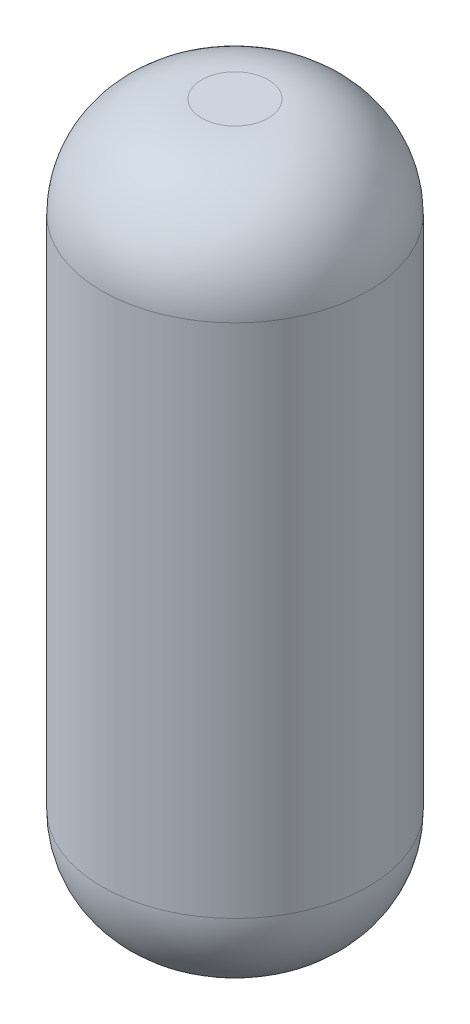
from build123d import *

# Parameters (mm, degrees)
CROQUIS1_R              = 4
SALIENTE_EXTRUIR1_DEPTH = 21.5
REDONDEO1_R             = 3


with BuildPart() as part:
    # Croquis1 → Saliente-Extruir1 (new body)
    with BuildSketch(Plane(origin=(0, 0, 0), x_dir=(1, 0, 0), z_dir=(0, 1, 0))):
        Circle(CROQUIS1_R)
    extrude(amount=SALIENTE_EXTRUIR1_DEPTH)

    # Redondeo1
    redondeo1_edges = [part.edges().sort_by_distance(p)[0] for p in [
        (-4, 0, 0),
        (-4, 21.5, 0),
    ]]
    fillet(redondeo1_edges, radius=REDONDEO1_R)


solid = part.part
